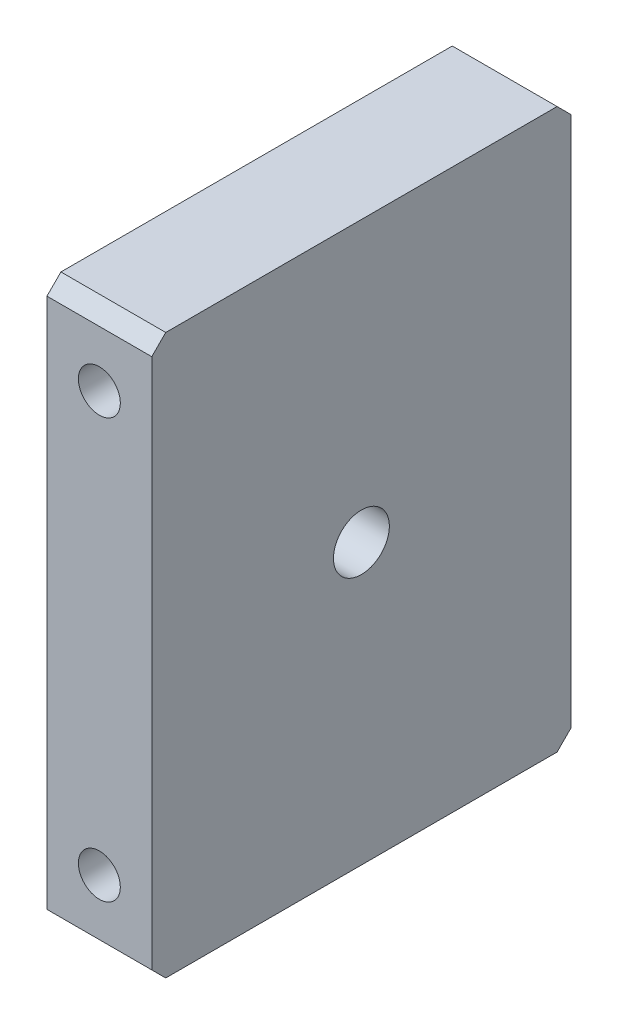
from build123d import *

# Parameters (mm, degrees)
SKETCH1_W           = 76.2
SKETCH1_H           = 101.6
BOSS_EXTRUDE1_DEPTH = 19.05
SKETCH3_R           = 3.81
CUT_EXTRUDE2_DEPTH  = 77.2
SKETCH6_R           = 3.81
CUT_EXTRUDE5_DEPTH  = 77.2
SKETCH5_R           = 5.08
CUT_EXTRUDE4_DEPTH  = 20.05
CHAMFER1_SIZE       = 2.54


with BuildPart() as part:
    # Sketch1 → Boss-Extrude1 (new body)
    with BuildSketch(Plane(origin=(0, 0, 0), x_dir=(0, 0, -1), z_dir=(1, 0, 0))):
        with Locations((38.1, 50.8)):
            Rectangle(SKETCH1_W, SKETCH1_H)
    extrude(amount=BOSS_EXTRUDE1_DEPTH)

    # Sketch3 → Cut-Extrude2 (cut, through all)
    with BuildSketch(Plane.XY):
        with Locations((9.525, 12.7)):
            Circle(SKETCH3_R)
    extrude(amount=-CUT_EXTRUDE2_DEPTH, mode=Mode.SUBTRACT)

    # Sketch6 → Cut-Extrude5 (cut, through all)
    with BuildSketch(Plane.XY):
        with Locations((9.525, 88.9)):
            Circle(SKETCH6_R)
    extrude(amount=-CUT_EXTRUDE5_DEPTH, mode=Mode.SUBTRACT)

    # Sketch5 → Cut-Extrude4 (cut, through all)
    with BuildSketch(Plane(origin=(19.05, 0, 0), x_dir=(0, 0, -1), z_dir=(1, 0, 0))):
        with Locations((38.1, 50.8)):
            Circle(SKETCH5_R)
    extrude(amount=-CUT_EXTRUDE4_DEPTH, mode=Mode.SUBTRACT)

    # Chamfer1
    chamfer1_edges = [part.edges().sort_by_distance(p)[0] for p in [
        (9.525, 0, 0),
        (9.525, 101.6, 0),
        (9.525, 101.6, -76.2),
        (9.525, 0, -76.2),
    ]]
    chamfer(chamfer1_edges, length=CHAMFER1_SIZE)


solid = part.part
